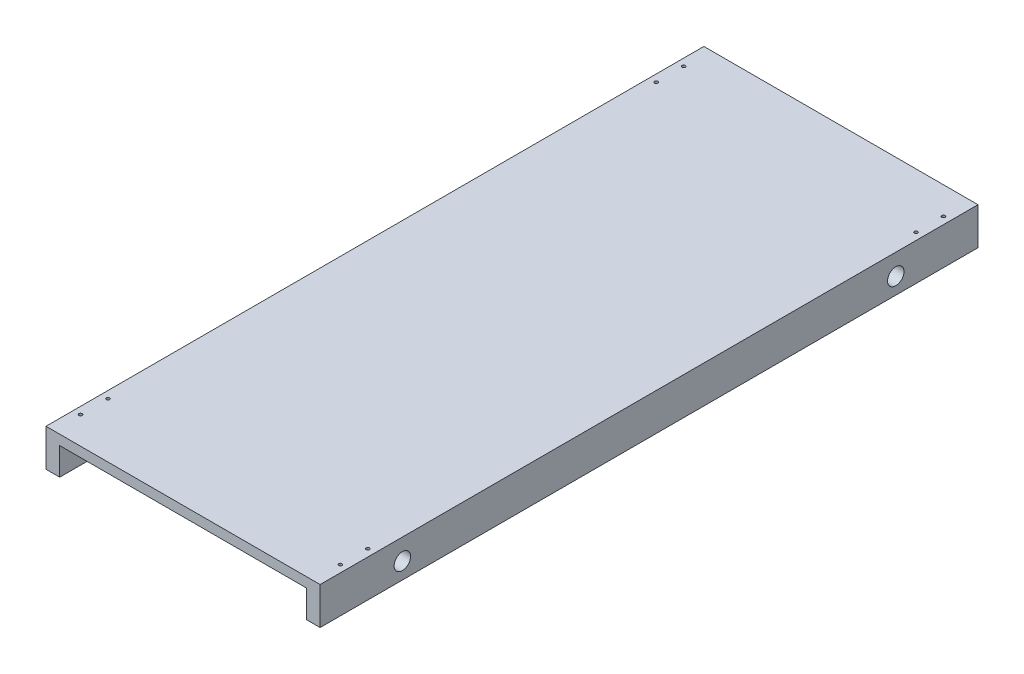
from build123d import *

# Parameters (mm, degrees)
SKETCH1_W                = 25
SKETCH1_H                = 50
SKETCH1_W_2              = 500
SKETCH1_H_2              = 18
BOSS_EXTRUDE1_DEPTH      = 1200
SKETCH2_R                = 15
CUT_EXTRUDE1_DEPTH       = 1
CUT_EXTRUDE1_DEPTH_BACK  = 501
F_6_0_6_DIAMETER_HOLE1_D = 6
LPATTERN1_COUNT          = 2
LPATTERN1_PITCH          = 50
LPATTERN1_COUNT_DIR2     = 2
LPATTERN1_PITCH_DIR2     = 474
LPATTERN2_COUNT          = 2
LPATTERN2_PITCH          = 1050
LPATTERN2_COPY_1_D       = 6
LPATTERN2_COPY_2_D       = 6
LPATTERN2_COPY_3_D       = 6


with BuildPart() as part:
    # Sketch1 → Boss-Extrude1 (new body)
    with BuildSketch(Plane.XY):
        with Locations((12.5, -25)):
            Rectangle(SKETCH1_W, SKETCH1_H)
        with Locations((250, 9)):
            Rectangle(SKETCH1_W_2, SKETCH1_H_2)
        with Locations((487.5, -25)):
            Rectangle(SKETCH1_W, SKETCH1_H)
    extrude(amount=BOSS_EXTRUDE1_DEPTH)

    # Sketch2 → Cut-Extrude1 (cut, two sides)
    with BuildSketch(Plane(origin=(500, 0, 0), x_dir=(0, 0, -1), z_dir=(1, 0, 0))) as cut_extrude1_sk:
        with Locations((-1050, -20)):
            Circle(SKETCH2_R)
        with Locations((-150, -20)):
            Circle(SKETCH2_R)
    extrude(amount=CUT_EXTRUDE1_DEPTH, mode=Mode.SUBTRACT)
    extrude(cut_extrude1_sk.sketch, amount=-CUT_EXTRUDE1_DEPTH_BACK, mode=Mode.SUBTRACT)

    # Ø6.0 (6) Diameter Hole1 (through all)
    with Locations(Plane(origin=(0, 18, 0), x_dir=(1, 0, 0), z_dir=(0, 1, 0))):
        with Locations((13, -1150)):
            f_6_0_6_diameter_hole1 = Hole(F_6_0_6_DIAMETER_HOLE1_D / 2)

    # LPattern1: 6.0 _6_ Diameter Hole1 2 × 2
    with Locations(*[(j * LPATTERN1_PITCH_DIR2, 0, -i * LPATTERN1_PITCH) for i in range(LPATTERN1_COUNT) for j in range(LPATTERN1_COUNT_DIR2) if (i, j) != (0, 0)]):
        add(f_6_0_6_diameter_hole1, mode=Mode.SUBTRACT)

    # LPattern2: Ø6.0 (6) Diameter Hole1 ×2
    with Locations(*[(0, 0, -i * LPATTERN2_PITCH) for i in range(1, LPATTERN2_COUNT)]):
        add(f_6_0_6_diameter_hole1, mode=Mode.SUBTRACT)

    # LPattern2 copy 1 (through all)
    with Locations(Plane(origin=(474, 18, -1050), x_dir=(1, 0, 0), z_dir=(0, 1, 0))):
        with Locations((13, -1150)):
            Hole(LPATTERN2_COPY_1_D / 2)

    # LPattern2 copy 2 (through all)
    with Locations(Plane(origin=(0, 18, -1100), x_dir=(1, 0, 0), z_dir=(0, 1, 0))):
        with Locations((13, -1150)):
            Hole(LPATTERN2_COPY_2_D / 2)

    # LPattern2 copy 3 (through all)
    with Locations(Plane(origin=(474, 18, -1100), x_dir=(1, 0, 0), z_dir=(0, 1, 0))):
        with Locations((13, -1150)):
            Hole(LPATTERN2_COPY_3_D / 2)


solid = part.part
